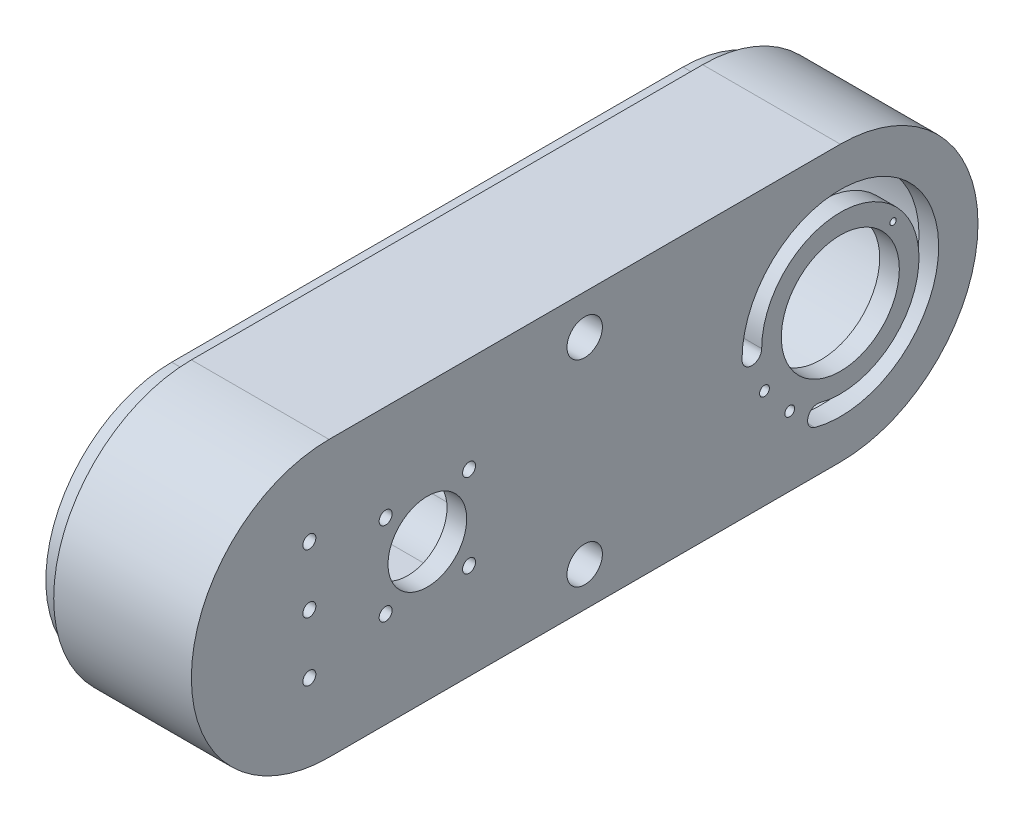
from build123d import *

# Parameters (mm, degrees)
EXTRUDE_1_DEPTH              = 35
CUT_EXTRUDE_2_DEPTH          = 30
SKETCH_2_R                   = 10
SKETCH_2_R_2                 = 15
CUT_EXTRUDE_1_DEPTH          = 1
CUT_EXTRUDE_1_DEPTH_BACK     = 36
EXTRUDE_2_DEPTH              = 5
CUT_EXTRUDE_4_REACH          = 42
SKETCH_11_R                  = 6
EXTRUDE_4_DEPTH              = 35
FILLET_1_R                   = 10
HOLE_WIZARD_M3_1_D           = 2.5
HOLE_WIZARD_M2_1_D           = 1.6
HOLE_WIZARD_M4_1_D           = 3.3
HOLE_WIZARD_M4_2_D           = 4.5
HOLE_WIZARD_M4_2_DEPTH       = 40
HOLE_WIZARD_M4_2_CBORE_D     = 9
HOLE_WIZARD_M4_2_CBORE_DEPTH = 33.1
HOLE_WIZARD_M4_2_TIP         = 1.351936393


with BuildPart() as part:
    # 스케치1 → 보스-돌출1 (new body)
    with BuildSketch(Plane(origin=(0, 0, 0), x_dir=(0, 0, -1), z_dir=(1, 0, 0))):
        with BuildLine():
            Line((-48.263014716, 12.710470067), (81.736985284, 12.710470067))
            ThreePointArc((81.736985284, 12.710470067), (116.736985284, -22.289529933), (81.736985284, -57.289529933))
            Line((81.736985284, -57.289529933), (-48.263014716, -57.289529933))
            ThreePointArc((-48.263014716, -57.289529933), (-83.263014716, -22.289529933), (-48.263014716, 12.710470067))
        make_face()
    extrude(amount=-EXTRUDE_1_DEPTH)

    # 스케치3 → 컷-돌출2 (cut)
    with BuildSketch(Plane.ZY.offset(35)):
        with BuildLine():
            Line((48.263014716, 7.710470067), (-81.736985284, 7.710470067))
            ThreePointArc((-81.736985284, 7.710470067), (-111.736985284, -22.289529933), (-81.736985284, -52.289529933))
            Line((-81.736985284, -52.289529933), (48.263014716, -52.289529933))
            ThreePointArc((48.263014716, -52.289529933), (78.263014716, -22.289529933), (48.263014716, 7.710470067))
        make_face()
    extrude(amount=-CUT_EXTRUDE_2_DEPTH, mode=Mode.SUBTRACT)

    # 스케치2 → 컷-돌출1 (cut, two sides)
    with BuildSketch(Plane(origin=(0, 0, 0), x_dir=(0, 0, -1), z_dir=(1, 0, 0))) as cut_extrude_1_sk:
        with Locations((-23.263014716, -22.302890454)):
            Circle(SKETCH_2_R)
        with Locations((81.736985284, -22.302890454)):
            Circle(SKETCH_2_R_2)
    extrude(amount=CUT_EXTRUDE_1_DEPTH, mode=Mode.SUBTRACT)
    extrude(cut_extrude_1_sk.sketch, amount=-CUT_EXTRUDE_1_DEPTH_BACK, mode=Mode.SUBTRACT)

    # 스케치6 → 보스-돌출2 (add)
    with BuildSketch(Plane.ZY.offset(35)):
        with BuildLine():
            Line((-81.736985284, -54.289529933), (48.263014716, -54.289529933))
            ThreePointArc((48.263014716, -54.289529933), (80.263014716, -22.289529933), (48.263014716, 9.710470067))
            Line((48.263014716, 9.710470067), (-81.736985284, 9.710470067))
            ThreePointArc((-81.736985284, 9.710470067), (-113.736985284, -22.289529933), (-81.736985284, -54.289529933))
        make_face()
        with BuildLine():
            Line((-81.736985284, -52.289529933), (48.263014716, -52.289529933))
            ThreePointArc((48.263014716, -52.289529933), (78.263014716, -22.289529933), (48.263014716, 7.710470067))
            Line((48.263014716, 7.710470067), (-81.736985284, 7.710470067))
            ThreePointArc((-81.736985284, 7.710470067), (-111.736985284, -22.289529933), (-81.736985284, -52.289529933))
        make_face(mode=Mode.SUBTRACT)
    extrude(amount=EXTRUDE_2_DEPTH)

    # 스케치8 → 컷-돌출4 (cut, up to next)
    with BuildSketch(Plane(origin=(0, 0, 0), x_dir=(0, 0, -1), z_dir=(1, 0, 0)), mode=Mode.PRIVATE) as cut_extrude_4_sk1:
        with BuildLine():
            ThreePointArc((76.560604382, -41.608046459), (97.60405209, -10.114301353), (61.736985284, -22.289529933))
            ThreePointArc((61.736985284, -22.289529933), (59.236985284, -24.789529933), (56.736985284, -22.289529933))
            ThreePointArc((56.736985284, -22.289529933), (101.570818791, -7.070494208), (75.266509157, -46.43767559))
            ThreePointArc((75.266509157, -46.43767559), (73.498742204, -43.375813412), (76.560604382, -41.608046459))
        make_face()
    cut_extrude_4_tool1 = extrude(cut_extrude_4_sk1.sketch, amount=-CUT_EXTRUDE_4_REACH, mode=Mode.PRIVATE) & part.part
    add(cut_extrude_4_tool1.solids().sort_by_distance((0, -43.558826, -74.181755))[0], mode=Mode.SUBTRACT)

    # 스케치11 → 보스-돌출4 (add)
    with BuildSketch(Plane.ZY.offset(5)):
        with Locations((-16.736985284, -47.289529933)):
            Circle(SKETCH_11_R)
        with Locations((-16.736985284, 2.710470067)):
            Circle(SKETCH_11_R)
    extrude(amount=EXTRUDE_4_DEPTH)

    # 필렛1
    fillet_1_edges = [part.edges().sort_by_distance(p)[0] for p in [
        (-22.5, -52.289529933, -20.053610075),
        (-22.5, -52.289529933, -13.420360494),
        (-22.5, 7.710470067, -13.420360494),
        (-22.5, 7.710470067, -20.053610075),
    ]]
    fillet(fillet_1_edges, radius=FILLET_1_R)

    # M3 나사 구멍1 (through all)
    with Locations(Plane.ZY.offset(5)):
        with Locations((-62.442692702, -31.965687796), (-68.870568799, -39.626132227)):
            Hole(HOLE_WIZARD_M3_1_D / 2)

    # M2 나사 구멍1 (through all)
    with Locations(Plane.ZY.offset(5)):
        with Locations((-95.142763039, -11.054107284)):
            Hole(HOLE_WIZARD_M2_1_D / 2)

    # M4 나사 구멍1 (through all)
    with Locations(Plane(origin=(0, 0, 0), x_dir=(0, 0, -1), z_dir=(1, 0, 0))):
        with Locations((-53.263014716, -7.302890454), (-53.263014716, -22.302890454), (-53.263014716, -37.302890454), (-33.869616434, -32.909492171), (-33.869616434, -11.696288736), (-12.656412998, -11.696288736), (-12.656412998, -32.909492171)):
            Hole(HOLE_WIZARD_M4_1_D / 2)

    # M4 남비 머리 나사용 카운터보어2
    with Locations(Plane(origin=(0, 0, 0), x_dir=(0, 0, -1), z_dir=(1, 0, 0))):
        with Locations((16.736985284, 2.710470067), (16.736985284, -47.289529933)):
            CounterBoreHole(HOLE_WIZARD_M4_2_D / 2, HOLE_WIZARD_M4_2_CBORE_D / 2, HOLE_WIZARD_M4_2_CBORE_DEPTH, depth=HOLE_WIZARD_M4_2_DEPTH)
            with Locations((0, 0, -(HOLE_WIZARD_M4_2_DEPTH + HOLE_WIZARD_M4_2_TIP / 2))):  # 118° drill point
                Cone(0, HOLE_WIZARD_M4_2_D / 2, HOLE_WIZARD_M4_2_TIP, mode=Mode.SUBTRACT)


solid = part.part
